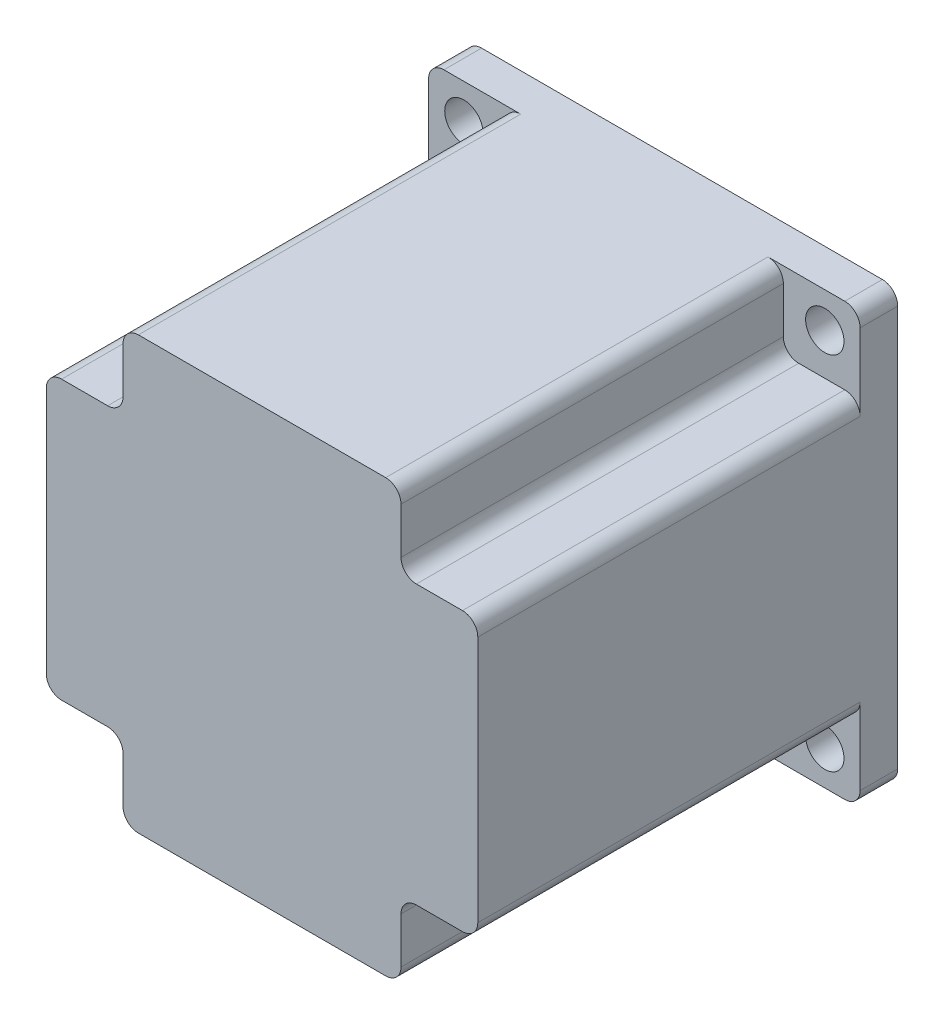
from build123d import *

# Parameters (mm, degrees)
SKETCH1_W           = 56.22
SKETCH1_H           = 56.22
BOSS_EXTRUDE1_DEPTH = 4.9
SKETCH2_R           = 2.5
CUT_EXTRUDE1_DEPTH  = 5.9
FILLET1_R           = 2
BOSS_EXTRUDE2_DEPTH = 49.81
FILLET2_R           = 2
SKETCH5_R           = 19.035
BOSS_EXTRUDE3_DEPTH = 1.6
SKETCH6_R           = 3.175
BOSS_EXTRUDE4_DEPTH = 19.37


with BuildPart() as part:
    # Sketch1 → Boss-Extrude1 (new body)
    with BuildSketch(Plane.XY):
        with Locations((28.11, 28.11)):
            Rectangle(SKETCH1_W, SKETCH1_H)
    extrude(amount=BOSS_EXTRUDE1_DEPTH)

    # Sketch2 → Cut-Extrude1 (cut, through all)
    with BuildSketch(Plane(origin=(0, 0, 0), x_dir=(-1, 0, 0), z_dir=(0, 0, -1))):
        with Locations((-4.6, 51.62)):
            Circle(SKETCH2_R)
        with Locations((-51.62, 51.62)):
            Circle(SKETCH2_R)
        with Locations((-51.62, 4.6)):
            Circle(SKETCH2_R)
        with Locations((-4.6, 4.6)):
            Circle(SKETCH2_R)
    extrude(amount=-CUT_EXTRUDE1_DEPTH, mode=Mode.SUBTRACT)

    # Fillet1
    fillet1_edges = [part.edges().sort_by_distance(p)[0] for p in [
        (0, 56.22, 2.45),
        (56.22, 56.22, 2.45),
        (56.22, 0, 2.45),
        (0, 0, 2.45),
    ]]
    fillet(fillet1_edges, radius=FILLET1_R)

    # Sketch4 → Boss-Extrude2 (add)
    with BuildSketch(Plane.XY.offset(4.9)):
        Polygon((0, 46.22), (0, 28.11), (28.11, 28.11), (28.11, 56.22), (10, 56.22), (10, 46.22), align=None)
        Polygon((28.11, 56.22), (28.11, 28.11), (56.22, 28.11), (56.22, 46.22), (46.22, 46.22), (46.22, 56.22), align=None)
        Polygon((56.22, 28.11), (28.11, 28.11), (28.11, 0), (46.22, 0), (46.22, 10), (56.22, 10), align=None)
        Polygon((28.11, 28.11), (0, 28.11), (0, 10), (10, 10), (10, 0), (28.11, 0), align=None)
    extrude(amount=BOSS_EXTRUDE2_DEPTH)

    # Fillet2
    fillet2_edges = [part.edges().sort_by_distance(p)[0] for p in [
        (10, 0, 29.805),
        (46.22, 0, 29.805),
        (46.22, 10, 29.805),
        (56.22, 10, 29.805),
        (56.22, 46.22, 29.805),
        (46.22, 46.22, 29.805),
        (46.22, 56.22, 29.805),
        (10, 56.22, 29.805),
        (10, 46.22, 29.805),
        (0, 46.22, 29.805),
        (0, 10, 29.805),
        (10, 10, 29.805),
    ]]
    fillet(fillet2_edges, radius=FILLET2_R)

    # Sketch5 → Boss-Extrude3 (add)
    with BuildSketch(Plane(origin=(0, 0, 0), x_dir=(-1, 0, 0), z_dir=(0, 0, -1))):
        with Locations((-28.11, 28.11)):
            Circle(SKETCH5_R)
    extrude(amount=BOSS_EXTRUDE3_DEPTH)

    # Sketch6 → Boss-Extrude4 (add)
    with BuildSketch(Plane(origin=(0, 0, -1.6), x_dir=(-1, 0, 0), z_dir=(0, 0, -1))):
        with Locations((-28.11, 28.11)):
            Circle(SKETCH6_R)
    extrude(amount=BOSS_EXTRUDE4_DEPTH)


solid = part.part
